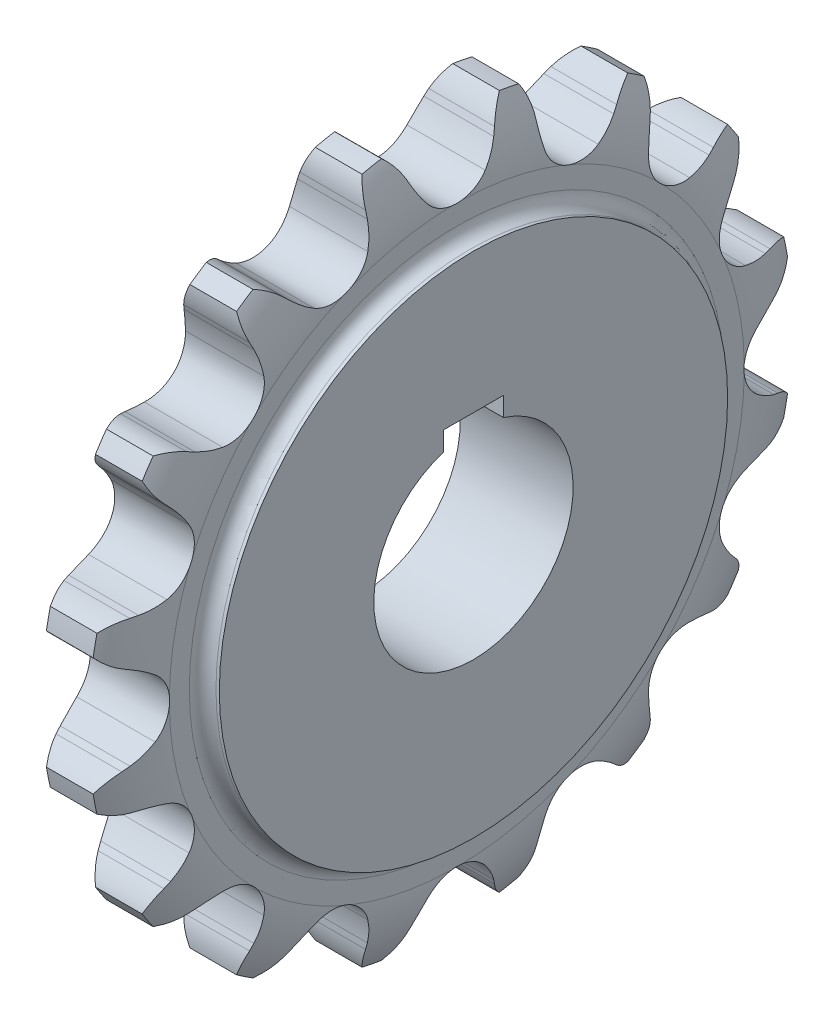
from build123d import *

# Parameters (mm, degrees)
EXTRUDECUTONE_DEPTH     = 16.995539279
PATTERNONE_COUNT        = 16
CUT_EXTRUDEB_DEPTH      = 149.761064598
CUT_EXTRUDEB_DEPTH_BACK = 149.761064598
SKETCHKEY_W             = 18
SKETCHKEY_H             = 19.400000095
CUT_EXTRUDE_3_REACH     = 153.646
SKETCH_3_R              = 30


with BuildPart() as part:
    # Sketch1 → Revolve 2 (revolve)
    with BuildSketch(Plane.XY):
        with BuildLine():
            Line((-16.995539279, 0), (-16.995539279, 76.5))
            Line((-16.995539279, 76.5), (-15.992331424, 76.5))
            ThreePointArc((-15.992331424, 76.5), (-13.154831112, 77.675331112), (-11.9795, 80.512831424))
            Line((-11.9795, 80.512831424), (-11.9795, 86.532078559))
            ThreePointArc((-11.9795, 86.532078559), (-10.809152515, 96.598348685), (-7.0265, 106))
            Line((-7.0265, 106), (7.0265, 106))
            ThreePointArc((7.0265, 106), (10.809152515, 96.598348685), (11.9795, 86.532078559))
            Line((11.9795, 86.532078559), (11.9795, 80.512831424))
            ThreePointArc((11.9795, 80.512831424), (13.154831112, 77.675331112), (15.992331424, 76.5))
            Line((15.992331424, 76.5), (16.995539279, 76.5))
            Line((16.995539279, 76.5), (16.995539279, 0))
            Line((16.995539279, 0), (-16.995539279, 0))
        make_face()
    revolve(axis=Axis((-4, 0, 0), (1, 0, 0)))

    # Sketch2 → ExtrudeCutOne (cut, symmetric)
    with BuildSketch(Plane(origin=(0, 0, 0), x_dir=(0, 0, -1), z_dir=(1, 0, 0))):
        with BuildLine():
            Line((12.575804928, 96.865775824), (13.416999248, 98.73315797))
            ThreePointArc((13.416999248, 98.73315797), (15.267606729, 101.859764085), (17.762236022, 104.501210383))
            ThreePointArc((17.762236022, 104.501210383), (0, 106), (-17.762236022, 104.501210383))
            ThreePointArc((-17.762236022, 104.501210383), (-15.267606729, 101.859764085), (-13.416999248, 98.73315797))
            Line((-13.416999248, 98.73315797), (-12.575804928, 96.865775824))
            ThreePointArc((-12.575804928, 96.865775824), (-10.860999948, 93.623652781), (-8.750752334, 90.623857295))
            ThreePointArc((-8.750752334, 90.623857295), (0, 86.426503559), (8.750752334, 90.623857295))
            ThreePointArc((8.750752334, 90.623857295), (10.860999948, 93.623652781), (12.575804928, 96.865775824))
        make_face()
    extrudecutone = extrude(amount=EXTRUDECUTONE_DEPTH, both=True, mode=Mode.SUBTRACT)

    # PatternOne: ExtrudeCutOne ×16 about axis
    patternone_axis = Axis((-4, 0, 0), (1, 0, 0))
    for i in range(1, PATTERNONE_COUNT):
        add(extrudecutone.rotate(patternone_axis, i * 360 / PATTERNONE_COUNT), mode=Mode.SUBTRACT)

    # SketchKey → Cut-ExtrudeB (cut, two sides: drawn at the far end of the back side and taken through both)
    with BuildSketch(Plane(origin=(0, 0, 0), x_dir=(0, 0, -1), z_dir=(1, 0, 0)).offset(-CUT_EXTRUDEB_DEPTH_BACK)):
        with Locations((0, 24.700000048)):
            Rectangle(SKETCHKEY_W, SKETCHKEY_H)
    extrude(amount=CUT_EXTRUDEB_DEPTH + CUT_EXTRUDEB_DEPTH_BACK, mode=Mode.SUBTRACT)

    # 草图3 → 切除-拉伸3 (cut, up to next)
    with BuildSketch(Plane(origin=(16.995539279, 0, 0), x_dir=(0, 0, -1), z_dir=(1, 0, 0)), mode=Mode.PRIVATE) as cut_extrude_3_sk1:
        Circle(SKETCH_3_R)
    cut_extrude_3_tool1 = extrude(cut_extrude_3_sk1.sketch, amount=-CUT_EXTRUDE_3_REACH, mode=Mode.PRIVATE) & part.part
    add(cut_extrude_3_tool1.solids().sort_by_distance((16.995539, 0, 0))[0], mode=Mode.SUBTRACT)


solid = part.part
